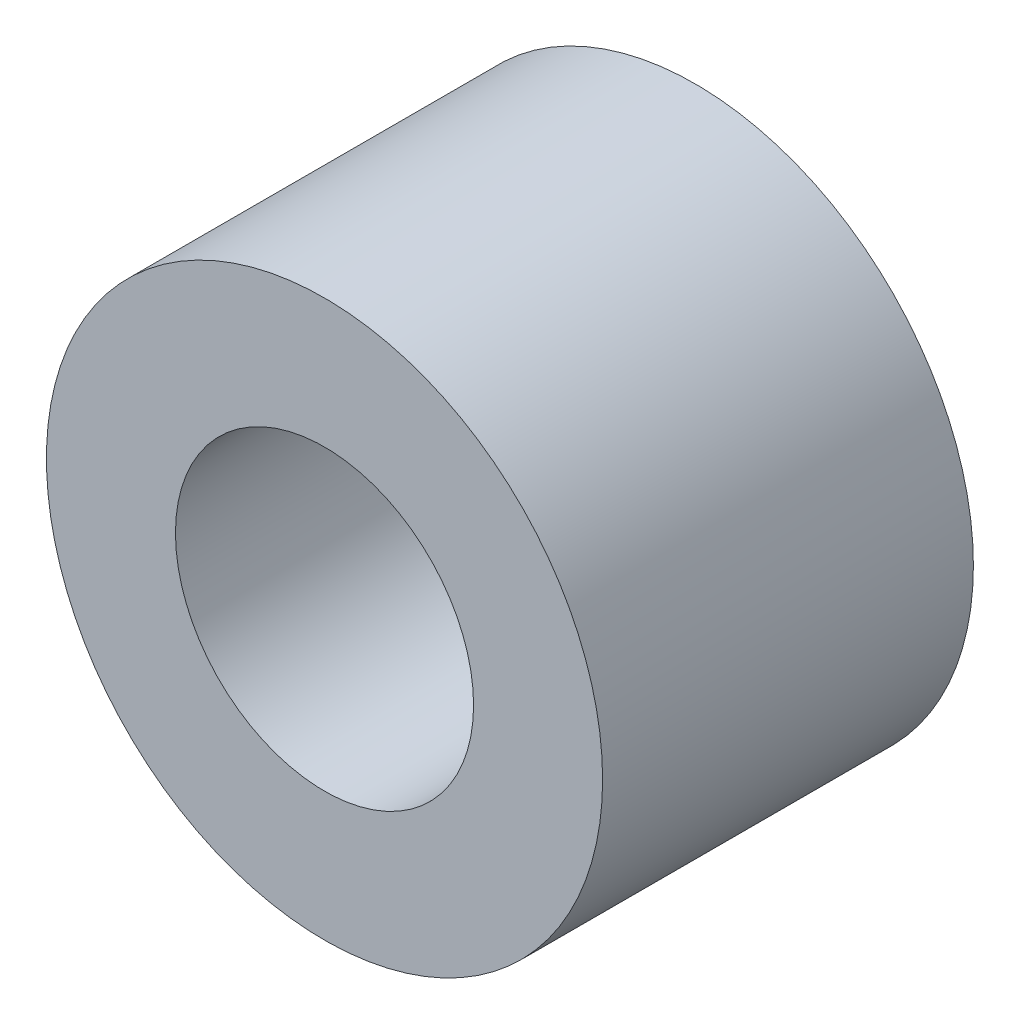
from build123d import *

# Parameters (mm, degrees)
SKETCH1_R           = 4.7625
SKETCH1_R_2         = 2.5527
BOSS_EXTRUDE1_DEPTH = 3.175


with BuildPart() as part:
    # Sketch1 → Boss-Extrude1 (new body, symmetric)
    with BuildSketch(Plane.XY):
        Circle(SKETCH1_R)
        Circle(SKETCH1_R_2, mode=Mode.SUBTRACT)
    extrude(amount=BOSS_EXTRUDE1_DEPTH, both=True)


solid = part.part
